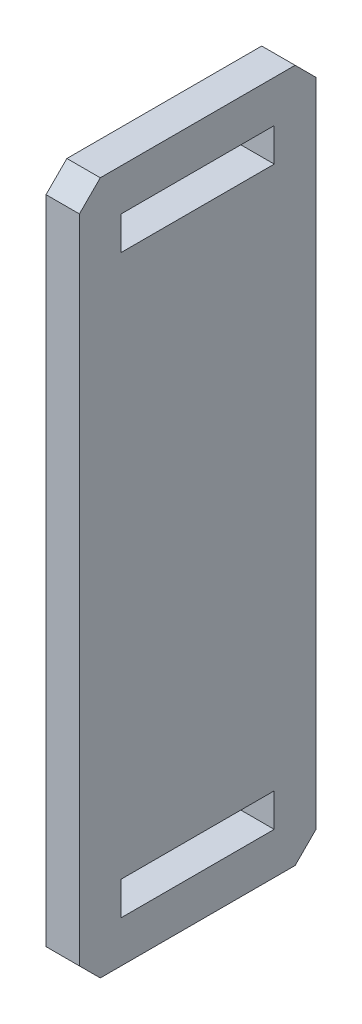
from build123d import *

# Parameters (mm, degrees)
SKETCH1_W           = 43.18
SKETCH1_H           = 126.492
SKETCH1_W_2         = 27.94
SKETCH1_H_2         = 6.096
BOSS_EXTRUDE1_DEPTH = 3.048
CHAMFER1_SIZE       = 3.81


with BuildPart() as part:
    # Sketch1 → Boss-Extrude1 (new, symmetric)
    with BuildSketch(Plane(origin=(0, 0, 0), x_dir=(0, 0, -1), z_dir=(1, 0, 0))):
        with Locations((-111.027292876, 0)):
            Rectangle(SKETCH1_W, SKETCH1_H)
        with Locations((-111.027292876, 52.578)):
            Rectangle(SKETCH1_W_2, SKETCH1_H_2, mode=Mode.SUBTRACT)
        with Locations((-111.027292876, -52.578)):
            Rectangle(SKETCH1_W_2, SKETCH1_H_2, mode=Mode.SUBTRACT)
    extrude(amount=BOSS_EXTRUDE1_DEPTH, both=True)

    # Chamfer1
    chamfer1_edges = [part.edges().sort_by_distance(p)[0] for p in [
        (0, -63.246, 89.437292876),
        (0, -63.246, 132.617292876),
        (0, 63.246, 89.437292876),
        (0, 63.246, 132.617292876),
    ]]
    chamfer(chamfer1_edges, length=CHAMFER1_SIZE)


solid = part.part
